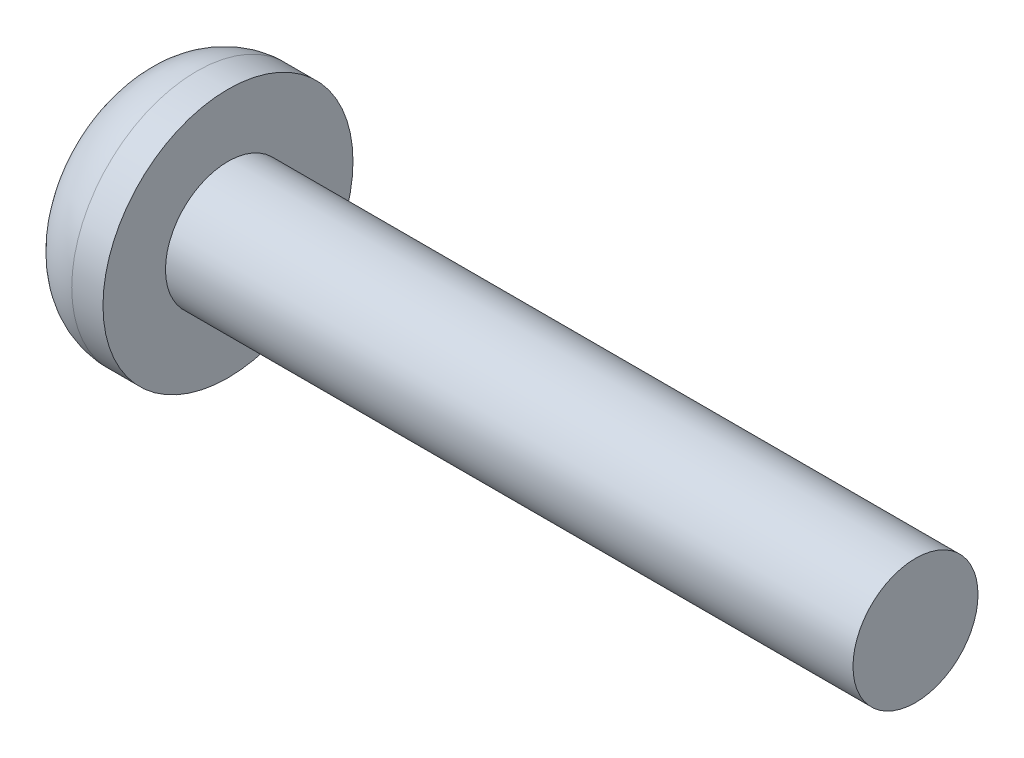
from build123d import *

# Parameters (mm, degrees)
SKETCH1_R           = 1
BOSS_EXTRUDE1_DEPTH = 11
SKETCH2_R           = 2
BOSS_EXTRUDE2_DEPTH = 1.5
FILLET1_R           = 1


with BuildPart() as part:
    # Sketch1 → Boss-Extrude1 (new body)
    with BuildSketch(Plane(origin=(0, 0, 0), x_dir=(0, 0, -1), z_dir=(1, 0, 0))):
        Circle(SKETCH1_R)
    extrude(amount=BOSS_EXTRUDE1_DEPTH)

    # Sketch2 → Boss-Extrude2 (add)
    with BuildSketch(Plane.ZY):
        Circle(SKETCH2_R)
    extrude(amount=BOSS_EXTRUDE2_DEPTH)

    # Fillet1
    fillet1_edges = [part.edges().sort_by_distance(p)[0] for p in [
        (-1.5, 0, -2),
    ]]
    fillet(fillet1_edges, radius=FILLET1_R)


solid = part.part
